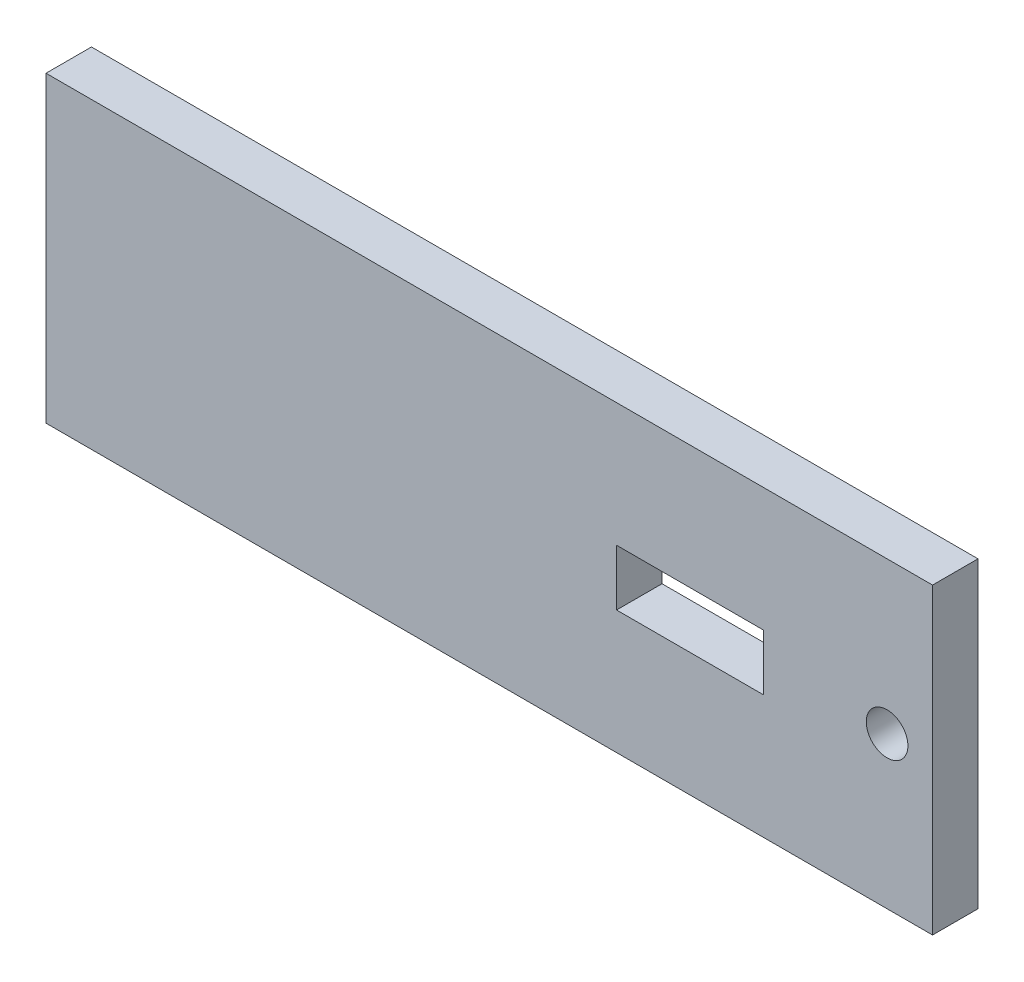
from build123d import *

# Parameters (mm, degrees)
EXTRUDE_1_DEPTH      = 10
EXTRUDE_1_DEPTH_BACK = 10
SKETCH_1_W           = 58.5
SKETCH_1_H           = 3
SKETCH_1_3_W         = 9.7
SKETCH_1_3_H         = 3
CUT_EXTRUDE_1_DEPTH  = 1.85
SKETCH_2_R           = 1.375
CUT_EXTRUDE_2_DEPTH  = 2


with BuildPart() as part:
    # 草圖1 → 填料-伸長1 (new, two sides: drawn at the far end of the back side and taken through both)
    with BuildSketch(Plane(origin=(0, 0, 0), x_dir=(1, 0, 0), z_dir=(0, 1, 0)).offset(-EXTRUDE_1_DEPTH_BACK)):
        with Locations((-24.00631853, -18.7)):
            Rectangle(SKETCH_1_W, SKETCH_1_H)
    extrude(amount=EXTRUDE_1_DEPTH + EXTRUDE_1_DEPTH_BACK)

    # 草圖1<3> → 除料-伸長1 (cut, symmetric)
    with BuildSketch(Plane(origin=(0, 0, 0), x_dir=(1, 0, 0), z_dir=(0, 1, 0))):
        with Locations((-10.75631853, -18.7)):
            Rectangle(SKETCH_1_3_W, SKETCH_1_3_H)
    extrude(amount=CUT_EXTRUDE_1_DEPTH, both=True, mode=Mode.SUBTRACT)

    # 草圖2 → 除料-伸長2 (cut)
    with BuildSketch(Plane.XY.offset(20.2)):
        with Locations((2.24368147, 0)):
            Circle(SKETCH_2_R)
    extrude(amount=-CUT_EXTRUDE_2_DEPTH, mode=Mode.SUBTRACT)


solid = part.part
